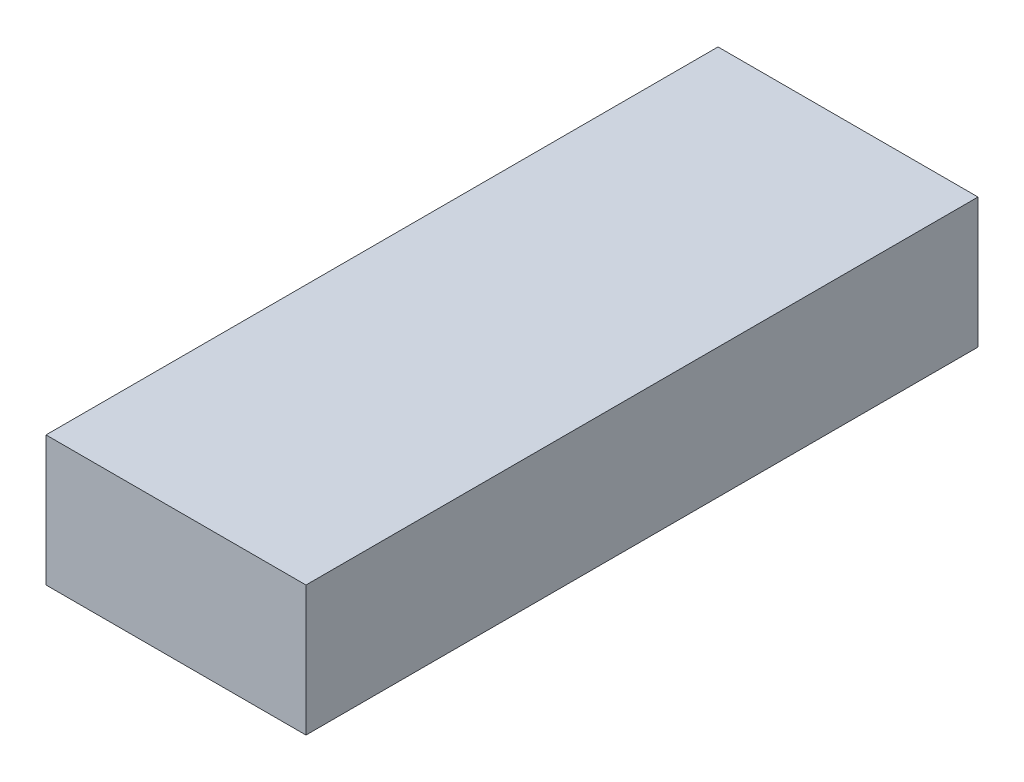
from build123d import *

# Parameters (mm, degrees)
SKETCH_1_W      = 20
SKETCH_1_H      = 10
EXTRUDE_1_DEPTH = 51.7


with BuildPart() as part:
    # Эскиз1 → Вытянуть1 (new body)
    with BuildSketch(Plane.XY):
        Rectangle(SKETCH_1_W, SKETCH_1_H)
    extrude(amount=EXTRUDE_1_DEPTH)


solid = part.part
